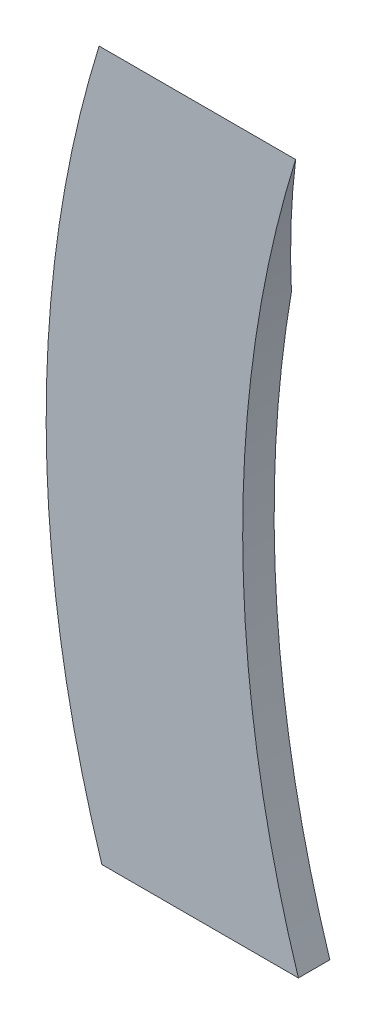
from build123d import *

# Parameters (mm, degrees)
EXTRUDE_1_DEPTH          = 4
CUT_EXTRUDE_1_DEPTH      = 94.493315269
CUT_EXTRUDE_1_DEPTH_BACK = 94.493315269
CUT_EXTRUDE_2_DEPTH      = 12
CUT_EXTRUDE_2_DEPTH_BACK = 94.493315269
SKETCH_3_W               = 2
SKETCH_3_H               = 50


with BuildPart() as part:
    # 草图1 → 凸台-拉伸1 (new body)
    with BuildSketch(Plane.XY):
        with BuildLine():
            Line((-0.350516392, 90), (24.649483608, 90))
            ThreePointArc((24.649483608, 90), (17.915567088, 44.973091345), (25, 0))
            Line((25, 0), (0, 0))
            ThreePointArc((0, 0), (-7.084432912, 44.973091345), (-0.350516392, 90))
        make_face()
    extrude(amount=EXTRUDE_1_DEPTH)

    # 草图2 → 切除-拉伸1 (cut, two sides: drawn at the far end of the back side and taken through both)
    with BuildSketch(Plane(origin=(0, 0, 0), x_dir=(0, 0, -1), z_dir=(1, 0, 0)).offset(-CUT_EXTRUDE_1_DEPTH_BACK)):
        Polygon((-4, 90), (0, 71.181479562), (0, 90), align=None)
    extrude(amount=CUT_EXTRUDE_1_DEPTH + CUT_EXTRUDE_1_DEPTH_BACK, mode=Mode.SUBTRACT)

    # 草图3 → 切除-拉伸2 (cut, two sides: drawn at the far end of the back side and taken through both)
    with BuildSketch(Plane(origin=(0, 0, 0), x_dir=(0, 0, -1), z_dir=(1, 0, 0)).offset(-CUT_EXTRUDE_2_DEPTH_BACK)):
        with Locations((-2, 45)):
            Rectangle(SKETCH_3_W, SKETCH_3_H)
    extrude(amount=CUT_EXTRUDE_2_DEPTH + CUT_EXTRUDE_2_DEPTH_BACK, mode=Mode.SUBTRACT)


solid = part.part
